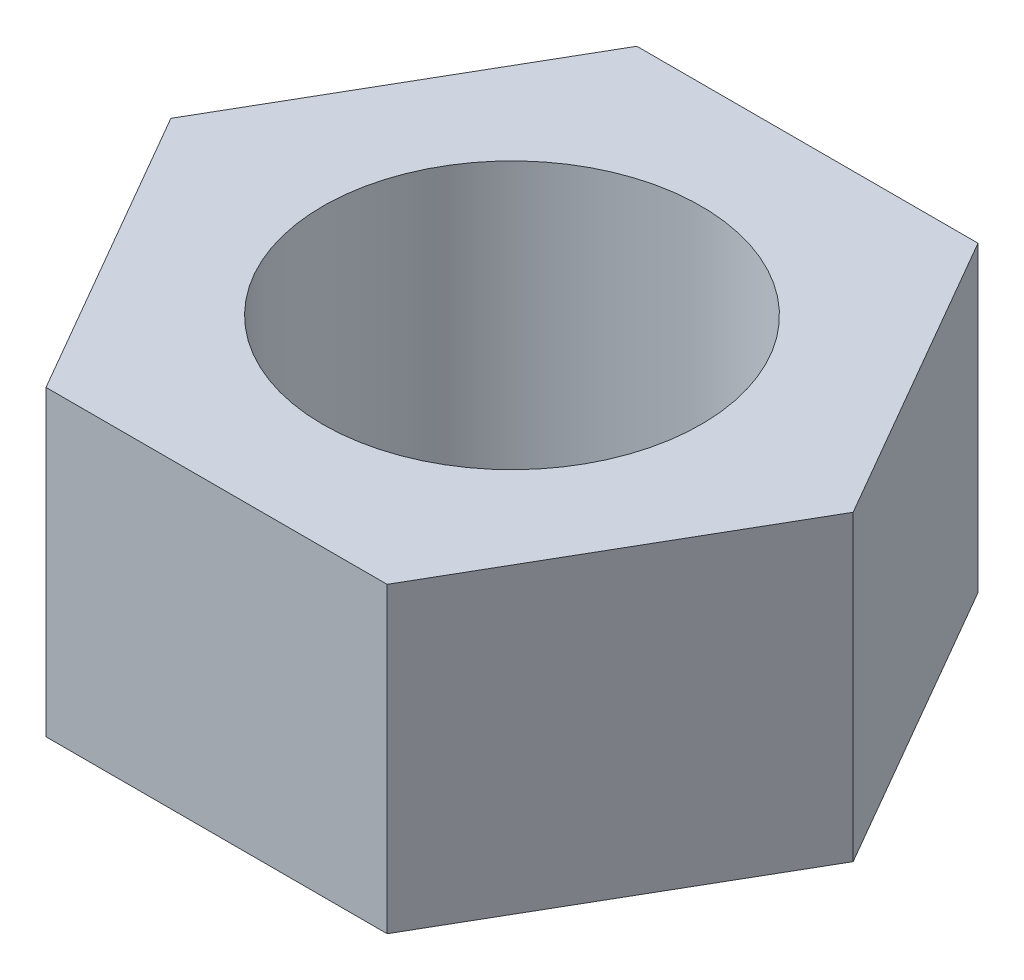
from build123d import *

# Parameters (mm, degrees)
SKETCH1_R           = 2.5
BOSS_EXTRUDE1_DEPTH = 4


with BuildPart() as part:
    # Sketch1 → Boss-Extrude1 (new body)
    with BuildSketch(Plane(origin=(0, 0, 0), x_dir=(1, 0, 0), z_dir=(0, 1, 0))):
        Polygon((-2.254697139, 3.90525), (-4.509394278, 0), (-2.254697139, -3.90525), (2.254697139, -3.90525), (4.509394278, 0), (2.254697139, 3.90525), align=None)
        Circle(SKETCH1_R, mode=Mode.SUBTRACT)
    extrude(amount=BOSS_EXTRUDE1_DEPTH)


solid = part.part
